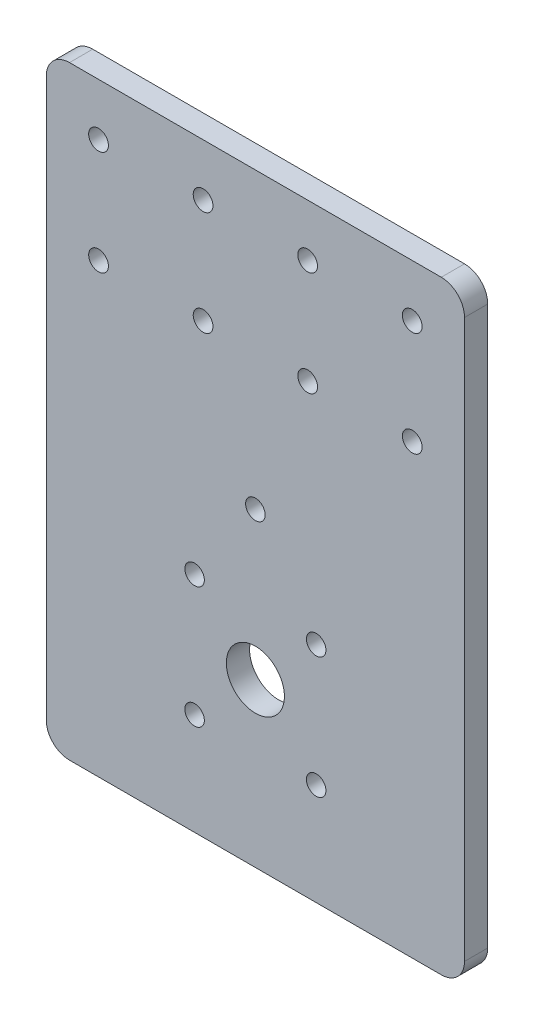
from build123d import *

# Parameters (mm, degrees)
SKETCH1_R           = 4.2
SKETCH1_R_2         = 4.25
SKETCH1_R_3         = 12.5
BOSS_EXTRUDE1_DEPTH = 10


with BuildPart() as part:
    # Sketch1 → Boss-Extrude1 (new body)
    with BuildSketch(Plane.XY):
        with BuildLine():
            Line((-80, -70), (80, -70))
            ThreePointArc((80, -70), (87.071067812, -67.071067812), (90, -60))
            Line((90, -60), (90, 180))
            ThreePointArc((90, 180), (87.071067812, 187.071067812), (80, 190))
            Line((80, 190), (-80, 190))
            ThreePointArc((-80, 190), (-87.071067812, 187.071067812), (-90, 180))
            Line((-90, 180), (-90, -60))
            ThreePointArc((-90, -60), (-87.071067812, -67.071067812), (-80, -70))
        make_face()
        with Locations((26.162950904, 26.162950904)):
            Circle(SKETCH1_R, mode=Mode.SUBTRACT)
        with Locations((26.162950904, -26.162950904)):
            Circle(SKETCH1_R, mode=Mode.SUBTRACT)
        with Locations((-26.162950904, -26.162950904)):
            Circle(SKETCH1_R, mode=Mode.SUBTRACT)
        with Locations((-26.162950904, 26.162950904)):
            Circle(SKETCH1_R, mode=Mode.SUBTRACT)
        with Locations((0, 63.5)):
            Circle(SKETCH1_R, mode=Mode.SUBTRACT)
        with Locations((-67.5, 167.5)):
            Circle(SKETCH1_R_2, mode=Mode.SUBTRACT)
        with Locations((-67.5, 122.5)):
            Circle(SKETCH1_R_2, mode=Mode.SUBTRACT)
        with Locations((-22.5, 122.5)):
            Circle(SKETCH1_R_2, mode=Mode.SUBTRACT)
        with Locations((-22.5, 167.5)):
            Circle(SKETCH1_R_2, mode=Mode.SUBTRACT)
        with Locations((22.5, 122.5)):
            Circle(SKETCH1_R_2, mode=Mode.SUBTRACT)
        with Locations((22.5, 167.5)):
            Circle(SKETCH1_R_2, mode=Mode.SUBTRACT)
        with Locations((67.5, 122.5)):
            Circle(SKETCH1_R_2, mode=Mode.SUBTRACT)
        with Locations((67.5, 167.5)):
            Circle(SKETCH1_R_2, mode=Mode.SUBTRACT)
        Circle(SKETCH1_R_3, mode=Mode.SUBTRACT)
    extrude(amount=BOSS_EXTRUDE1_DEPTH)


solid = part.part
